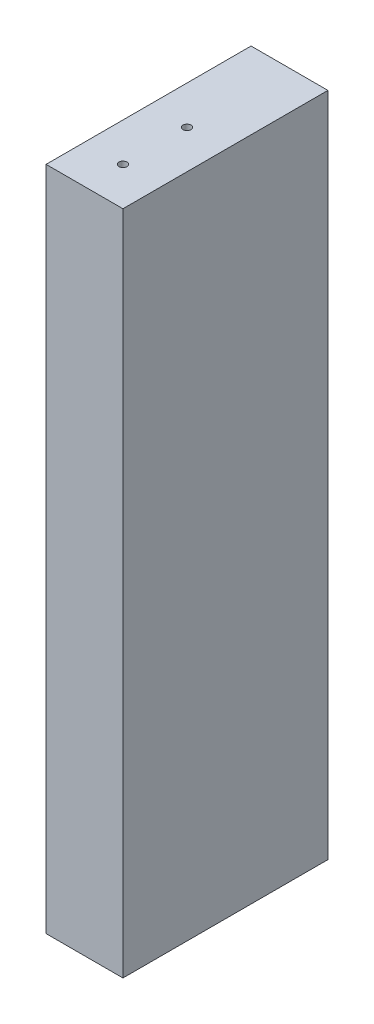
from build123d import *

# Parameters (mm, degrees)
SKETCH1_W                           = 19.05
SKETCH1_H                           = 165.099999729
BOSS_EXTRUDE1_DEPTH                 = 50.8
F_5_64_0_07813_DIAMETER_HOLE1_D     = 1.984502
F_5_64_0_07813_DIAMETER_HOLE1_DEPTH = 38.1
F_5_64_0_07813_DIAMETER_HOLE1_TIP   = 0.59620455
F_5_64_0_07813_DIAMETER_HOLE2_D     = 1.984502
F_5_64_0_07813_DIAMETER_HOLE2_DEPTH = 19.05
F_5_64_0_07813_DIAMETER_HOLE2_TIP   = 0.59620455
F_5_64_0_07813_DIAMETER_HOLE3_D     = 1.984502
F_5_64_0_07813_DIAMETER_HOLE3_DEPTH = 19.05
F_5_64_0_07813_DIAMETER_HOLE3_TIP   = 0.59620455


with BuildPart() as part:
    # Sketch1 → Boss-Extrude1 (new body)
    with BuildSketch(Plane.XY):
        with Locations((440.567640906, 6183.630000136)):
            Rectangle(SKETCH1_W, SKETCH1_H)
    extrude(amount=BOSS_EXTRUDE1_DEPTH)

    # 5/64 (0.07813) Diameter Hole1
    with Locations(Plane(origin=(4.968994719, 3.22e-07, -19.050107671), x_dir=(-1, 0, 0), z_dir=(0, 0, -1))):
        with Locations((-481.589248274, 6993.254992531), (-386.339248274, 6993.254992531), (-291.089248274, 6993.254992531), (-295.274999999, 6965.135938475), (-295.274999999, 6812.735938475), (-295.274999999, 6660.335938474), (-285.166362357, 6631.468843414), (-475.477307398, 6631.468752771), (-485.002307398, 6660.335938474), (-485.002307398, 6812.735938474), (-485.002307398, 6965.135938474), (-478.365617646, 6611.6708), (-287.865617646, 6611.6708), (-307.975, 6564.3379), (-307.975, 6488.1379), (-284.960913066, 6440.805), (-380.210913066, 6440.805), (-475.460913066, 6440.805), (-446.831312422, 6488.1379), (-446.831312422, 6564.3379), (-472.231312422, 6396.355), (-472.231312422, 6320.155), (-472.653156211, 6275.705000839), (-377.403156211, 6275.705000839), (-282.153156211, 6275.705000839), (-282.575, 6320.155), (-282.575, 6396.355), (-435.598646187, 6221.729999816), (-435.598646187, 6145.529999816), (-450.592518112, 6091.554999951), (-460.998646187, 6091.555478285), (-460.998646187, 6056.629999944), (-460.998646187, 5980.429999944), (-460.998646187, 5945.505000042), (-282.153156211, 5945.505000042), (-368.611823093, 5945.505000042)):
            Hole(F_5_64_0_07813_DIAMETER_HOLE1_D / 2, depth=F_5_64_0_07813_DIAMETER_HOLE1_DEPTH)
            with Locations((0, 0, -(F_5_64_0_07813_DIAMETER_HOLE1_DEPTH + F_5_64_0_07813_DIAMETER_HOLE1_TIP / 2))):  # 118° drill point
                Cone(0, F_5_64_0_07813_DIAMETER_HOLE1_D / 2, F_5_64_0_07813_DIAMETER_HOLE1_TIP, mode=Mode.SUBTRACT)

    # 5/64 (0.07813) Diameter Hole2
    with Locations(Plane(origin=(0, 6101.080000271, 0), x_dir=(-1, 0, 0), z_dir=(0, -1, 0))):
        with Locations((-440.567640906, -41.274956045), (-440.567640906, -25.399956045)):
            Hole(F_5_64_0_07813_DIAMETER_HOLE2_D / 2, depth=F_5_64_0_07813_DIAMETER_HOLE2_DEPTH)
            with Locations((0, 0, -(F_5_64_0_07813_DIAMETER_HOLE2_DEPTH + F_5_64_0_07813_DIAMETER_HOLE2_TIP / 2))):  # 118° drill point
                Cone(0, F_5_64_0_07813_DIAMETER_HOLE2_D / 2, F_5_64_0_07813_DIAMETER_HOLE2_TIP, mode=Mode.SUBTRACT)

    # 5/64 (0.07813) Diameter Hole3
    with Locations(Plane(origin=(0, 6266.18, 0), x_dir=(1, 0, 0), z_dir=(0, 1, 0))):
        with Locations((440.567640906, -25.399956045), (440.567640906, -41.274956045)):
            Hole(F_5_64_0_07813_DIAMETER_HOLE3_D / 2, depth=F_5_64_0_07813_DIAMETER_HOLE3_DEPTH)
            with Locations((0, 0, -(F_5_64_0_07813_DIAMETER_HOLE3_DEPTH + F_5_64_0_07813_DIAMETER_HOLE3_TIP / 2))):  # 118° drill point
                Cone(0, F_5_64_0_07813_DIAMETER_HOLE3_D / 2, F_5_64_0_07813_DIAMETER_HOLE3_TIP, mode=Mode.SUBTRACT)


solid = part.part
